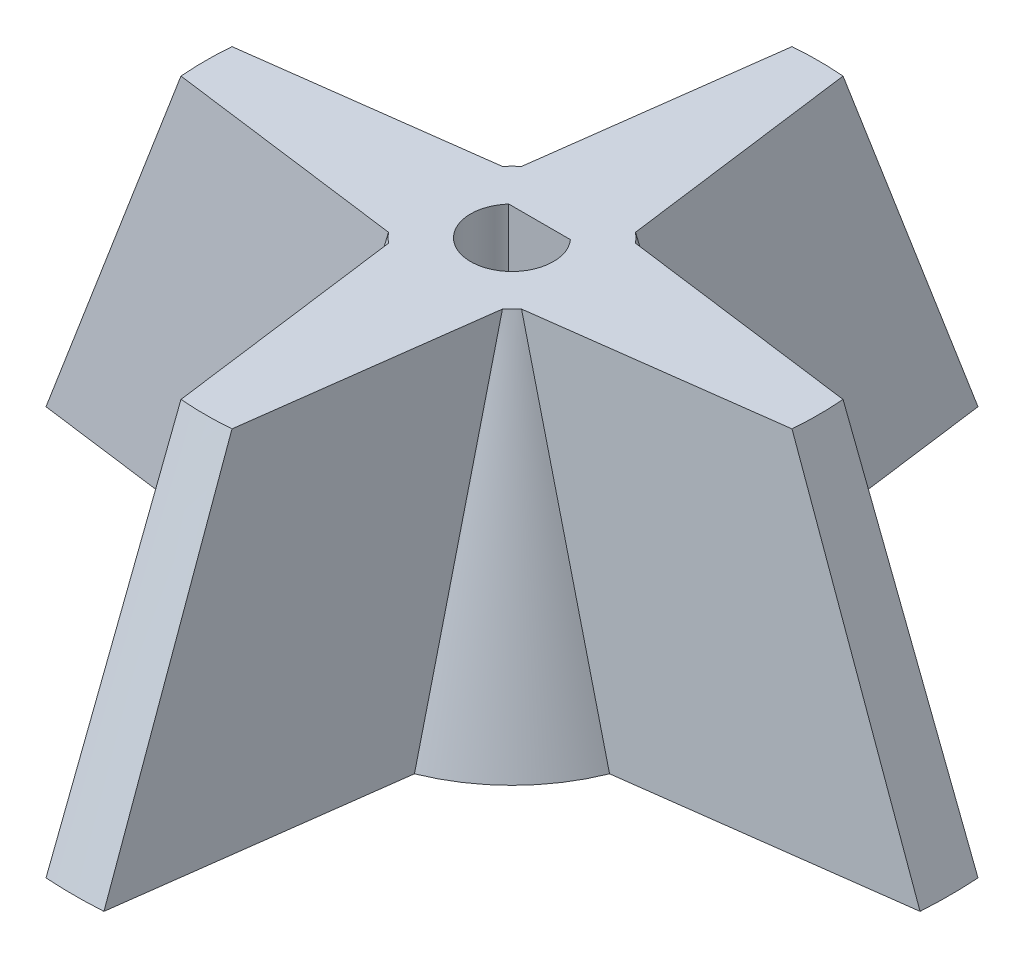
from build123d import *

# Parameters (mm, degrees)
CUT_EXTRUDE1_DEPTH      = 26.4000001
CUT_EXTRUDE1_DEPTH_BACK = 1.0000001


with BuildPart() as part:
    # Sketch2 → Loft1 section 0
    with BuildSketch(Plane(origin=(0, 0, 0), x_dir=(1, 0, 0), z_dir=(0, 1, 0))):
        with BuildLine():
            Line((-4.71851035, 11.790914302), (-2.1, 31.68047506))
            ThreePointArc((-2.1, 31.68047506), (0, 31.75), (2.1, 31.68047506))
            Line((2.1, 31.68047506), (4.71851035, 11.790914302))
            ThreePointArc((4.71851035, 11.790914302), (8.980256121, 8.980256121), (11.790914302, 4.71851035))
            Line((11.790914302, 4.71851035), (31.68047506, 2.1))
            ThreePointArc((31.68047506, 2.1), (31.75, 0), (31.68047506, -2.1))
            Line((31.68047506, -2.1), (11.790914302, -4.71851035))
            ThreePointArc((11.790914302, -4.71851035), (8.980256121, -8.980256121), (4.71851035, -11.790914302))
            Line((4.71851035, -11.790914302), (2.1, -31.68047506))
            ThreePointArc((2.1, -31.68047506), (0, -31.75), (-2.1, -31.68047506))
            Line((-2.1, -31.68047506), (-4.71851035, -11.790914302))
            ThreePointArc((-4.71851035, -11.790914302), (-8.980256121, -8.980256121), (-11.790914302, -4.71851035))
            Line((-11.790914302, -4.71851035), (-31.68047506, -2.1))
            ThreePointArc((-31.68047506, -2.1), (-31.75, 0), (-31.68047506, 2.1))
            Line((-31.68047506, 2.1), (-11.790914302, 4.71851035))
            ThreePointArc((-11.790914302, 4.71851035), (-8.980256121, 8.980256121), (-4.71851035, 11.790914302))
        make_face()
    # Sketch5 → Loft1 section 1
    with BuildSketch(Plane(origin=(0, 25.4, 0), x_dir=(1, 0, 0), z_dir=(0, 1, 0))):
        with BuildLine():
            Line((-4.13090623, 4.822666661), (-1.85, 22.147869536))
            ThreePointArc((-1.85, 22.147869536), (0, 22.225), (1.85, 22.147869536))
            Line((1.85, 22.147869536), (4.13090623, 4.822666661))
            ThreePointArc((4.13090623, 4.822666661), (4.490128061, 4.490128061), (4.822666661, 4.13090623))
            Line((4.822666661, 4.13090623), (22.147869536, 1.85))
            ThreePointArc((22.147869536, 1.85), (22.225, 0), (22.147869536, -1.85))
            Line((22.147869536, -1.85), (4.822666661, -4.13090623))
            ThreePointArc((4.822666661, -4.13090623), (4.490128061, -4.490128061), (4.13090623, -4.822666661))
            Line((4.13090623, -4.822666661), (1.85, -22.147869536))
            ThreePointArc((1.85, -22.147869536), (0, -22.225), (-1.85, -22.147869536))
            Line((-1.85, -22.147869536), (-4.13090623, -4.822666661))
            ThreePointArc((-4.13090623, -4.822666661), (-4.490128061, -4.490128061), (-4.822666661, -4.13090623))
            Line((-4.822666661, -4.13090623), (-22.147869536, -1.85))
            ThreePointArc((-22.147869536, -1.85), (-22.225, 0), (-22.147869536, 1.85))
            Line((-22.147869536, 1.85), (-4.822666661, 4.13090623))
            ThreePointArc((-4.822666661, 4.13090623), (-4.490128061, 4.490128061), (-4.13090623, 4.822666661))
        make_face()
    loft()

    # Sketch2_3 → Cut-Extrude1 (cut, two sides)
    with BuildSketch(Plane(origin=(0, 0, 0), x_dir=(1, 0, 0), z_dir=(0, 1, 0))) as cut_extrude1_sk:
        with BuildLine():
            ThreePointArc((2.236067977, 2), (0, -3), (-2.236067977, 2))
            Line((-2.236067977, 2), (2.236067977, 2))
        make_face()
    extrude(amount=CUT_EXTRUDE1_DEPTH, mode=Mode.SUBTRACT)
    extrude(cut_extrude1_sk.sketch, amount=-CUT_EXTRUDE1_DEPTH_BACK, mode=Mode.SUBTRACT)


solid = part.part
